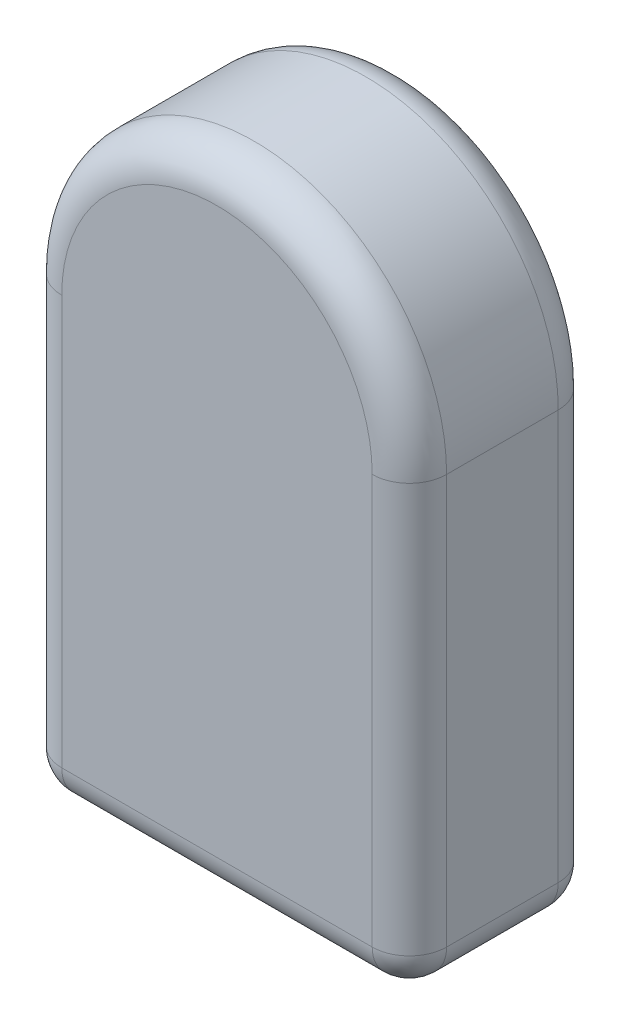
from build123d import *

# Parameters (mm, degrees)
BOSS_EXTRUDE1_DEPTH = 5
FILLET2_R           = 1


with BuildPart() as part:
    # Sketch1 → Boss-Extrude1 (new body)
    with BuildSketch(Plane.XY):
        with BuildLine():
            Line((-9.132007365, 0), (-9.132007365, 12))
            ThreePointArc((-9.132007365, 12), (-3.960686979, 17.171320386), (1.210633407, 12))
            Line((1.210633407, 12), (1.210633407, 0))
            Line((1.210633407, 0), (-9.132007365, 0))
        make_face()
    extrude(amount=BOSS_EXTRUDE1_DEPTH)

    # Fillet2
    fillet2_edges = [part.edges().sort_by_distance(p)[0] for p in [
        (-3.960686979, 17.171320386, 5),
        (-9.132007365, 6, 5),
        (-3.960686979, 0, 5),
        (-9.132007365, 6, 0),
        (-3.960686979, 17.171320386, 0),
        (1.210633407, 6, 0),
        (-3.960686979, 0, 0),
        (1.210633407, 6, 5),
        (-9.132007365, 0, 2.5),
        (1.210633407, 0, 2.5),
    ]]
    fillet(fillet2_edges, radius=FILLET2_R)


solid = part.part
